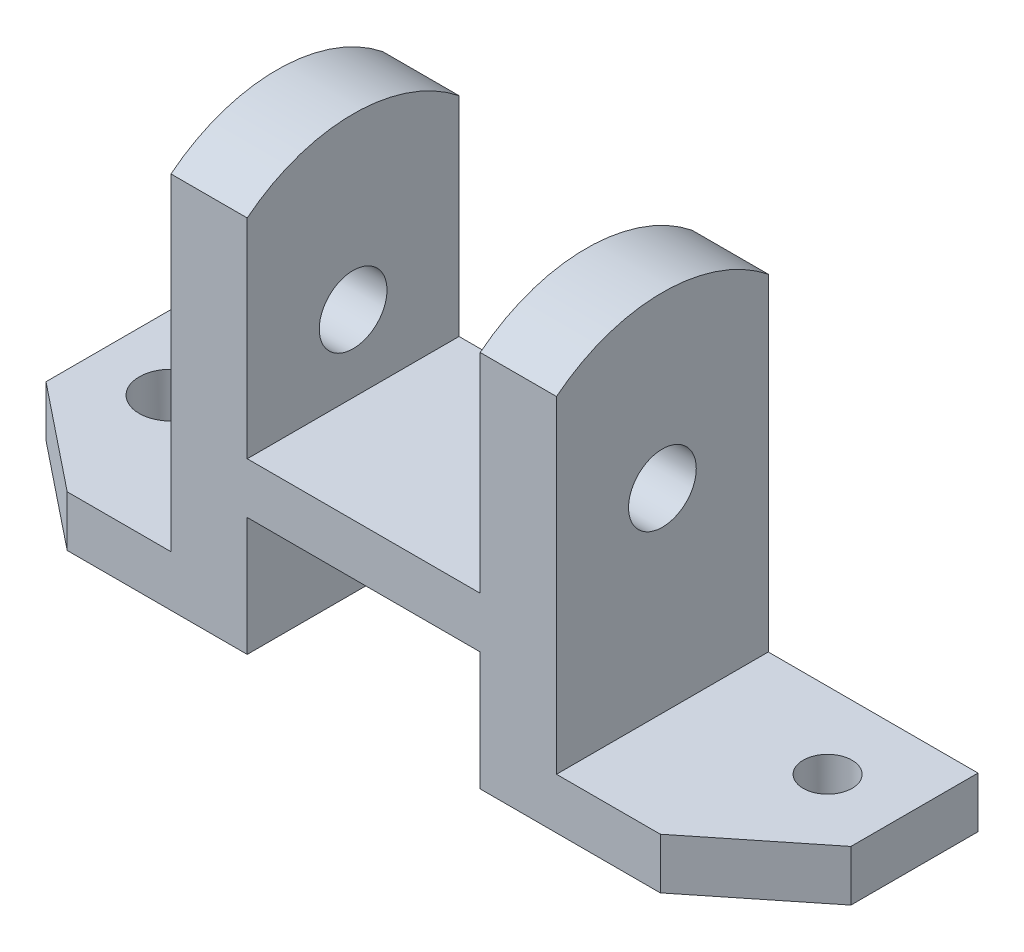
from build123d import *

# Parameters (mm, degrees)
SKETCH1_W               = 91
SKETCH1_H               = 50
BOSS_EXTRUDE1_DEPTH     = 12
SKETCH2_W               = 18
SKETCH2_H               = 50
BOSS_EXTRUDE2_DEPTH     = 28
SKETCH4_W               = 50
SKETCH4_H               = 12
BOSS_EXTRUDE3_DEPTH     = 49.5
SKETCH5_W               = 50
SKETCH5_H               = 12
BOSS_EXTRUDE4_DEPTH     = 49.5
CUT_EXTRUDE1_DEPTH      = 29
CUT_EXTRUDE1_DEPTH_BACK = 13
CUT_EXTRUDE2_DEPTH      = 29
CUT_EXTRUDE2_DEPTH_BACK = 13
SKETCH9_W               = 18
SKETCH9_H               = 50
BOSS_EXTRUDE5_DEPTH     = 58
SKETCH10_R              = 8
CUT_EXTRUDE3_DEPTH      = 50.5
CUT_EXTRUDE3_DEPTH_BACK = 141.5
SKETCH12_R              = 5.769053465
SKETCH12_R_2            = 7.5
CUT_EXTRUDE4_DEPTH      = 59
CUT_EXTRUDE4_DEPTH_BACK = 41
SKETCH15_W              = 55
SKETCH15_H              = 8
BOSS_EXTRUDE6_DEPTH     = 28


with BuildPart() as part:
    # Sketch1 → Boss-Extrude1 (new body)
    with BuildSketch(Plane(origin=(0, 0, 0), x_dir=(1, 0, 0), z_dir=(0, 1, 0))):
        Rectangle(SKETCH1_W, SKETCH1_H)
    extrude(amount=-BOSS_EXTRUDE1_DEPTH)

    # Sketch2 → Boss-Extrude2 (add)
    with BuildSketch(Plane.XZ.offset(12)):
        with Locations((-36.5, 0)):
            Rectangle(SKETCH2_W, SKETCH2_H)
        with Locations((36.5, 0)):
            Rectangle(SKETCH2_W, SKETCH2_H)
    extrude(amount=BOSS_EXTRUDE2_DEPTH)

    # Sketch4 → Boss-Extrude3 (add)
    with BuildSketch(Plane(origin=(45.5, 0, 0), x_dir=(0, 0, -1), z_dir=(1, 0, 0))):
        with Locations((0, -34)):
            Rectangle(SKETCH4_W, SKETCH4_H)
    extrude(amount=BOSS_EXTRUDE3_DEPTH)

    # Sketch5 → Boss-Extrude4 (add)
    with BuildSketch(Plane.ZY.offset(45.5)):
        with Locations((0, -34)):
            Rectangle(SKETCH5_W, SKETCH5_H)
    extrude(amount=BOSS_EXTRUDE4_DEPTH)

    # Sketch7 → Cut-Extrude1 (cut, two sides)
    with BuildSketch(Plane(origin=(0, -28, 0), x_dir=(1, 0, 0), z_dir=(0, 1, 0))) as cut_extrude1_sk:
        Polygon((95, -25), (95, -5), (70, -25), align=None)
    extrude(amount=CUT_EXTRUDE1_DEPTH, mode=Mode.SUBTRACT)
    extrude(cut_extrude1_sk.sketch, amount=-CUT_EXTRUDE1_DEPTH_BACK, mode=Mode.SUBTRACT)

    # Sketch8 → Cut-Extrude2 (cut, two sides)
    with BuildSketch(Plane(origin=(0, -28, 0), x_dir=(1, 0, 0), z_dir=(0, 1, 0))) as cut_extrude2_sk:
        Polygon((-95, -25), (-95, -5), (-70, -25), align=None)
    extrude(amount=CUT_EXTRUDE2_DEPTH, mode=Mode.SUBTRACT)
    extrude(cut_extrude2_sk.sketch, amount=-CUT_EXTRUDE2_DEPTH_BACK, mode=Mode.SUBTRACT)

    # Sketch9 → Boss-Extrude5 (add)
    with BuildSketch(Plane(origin=(0, 0, 0), x_dir=(1, 0, 0), z_dir=(0, 1, 0))):
        with Locations((-36.5, 0)):
            Rectangle(SKETCH9_W, SKETCH9_H)
        with Locations((36.5, 0)):
            Rectangle(SKETCH9_W, SKETCH9_H)
    extrude(amount=BOSS_EXTRUDE5_DEPTH)

    # Sketch10 → Cut-Extrude3 (cut, two sides)
    with BuildSketch(Plane(origin=(45.5, 0, 0), x_dir=(0, 0, -1), z_dir=(1, 0, 0))) as cut_extrude3_sk:
        with BuildLine():
            Line((25, 58), (0, 58))
            ThreePointArc((0, 58), (13.247648854, 55.742546282), (25, 49.224989992))
            Line((25, 49.224989992), (25, 58))
        make_face()
        with BuildLine():
            Line((-25, 58), (-25, 49.224989992))
            ThreePointArc((-25, 49.224989992), (-13.247648854, 55.742546282), (0, 58))
            Line((0, 58), (-25, 58))
        make_face()
        with Locations((0, 18)):
            Circle(SKETCH10_R)
    extrude(amount=CUT_EXTRUDE3_DEPTH, mode=Mode.SUBTRACT)
    extrude(cut_extrude3_sk.sketch, amount=-CUT_EXTRUDE3_DEPTH_BACK, mode=Mode.SUBTRACT)

    # Sketch12 → Cut-Extrude4 (cut, two sides)
    with BuildSketch(Plane(origin=(0, 0, 0), x_dir=(1, 0, 0), z_dir=(0, 1, 0))) as cut_extrude4_sk:
        with Locations((77.5, 7)):
            Circle(SKETCH12_R)
        with Locations((-77.5, 7)):
            Circle(SKETCH12_R_2)
    extrude(amount=CUT_EXTRUDE4_DEPTH, mode=Mode.SUBTRACT)
    extrude(cut_extrude4_sk.sketch, amount=-CUT_EXTRUDE4_DEPTH_BACK, mode=Mode.SUBTRACT)

    # Sketch15 → Boss-Extrude6 (add)
    with BuildSketch(Plane.XZ.offset(12)):
        with Locations((0, -7)):
            Rectangle(SKETCH15_W, SKETCH15_H)
    extrude(amount=BOSS_EXTRUDE6_DEPTH)


solid = part.part
